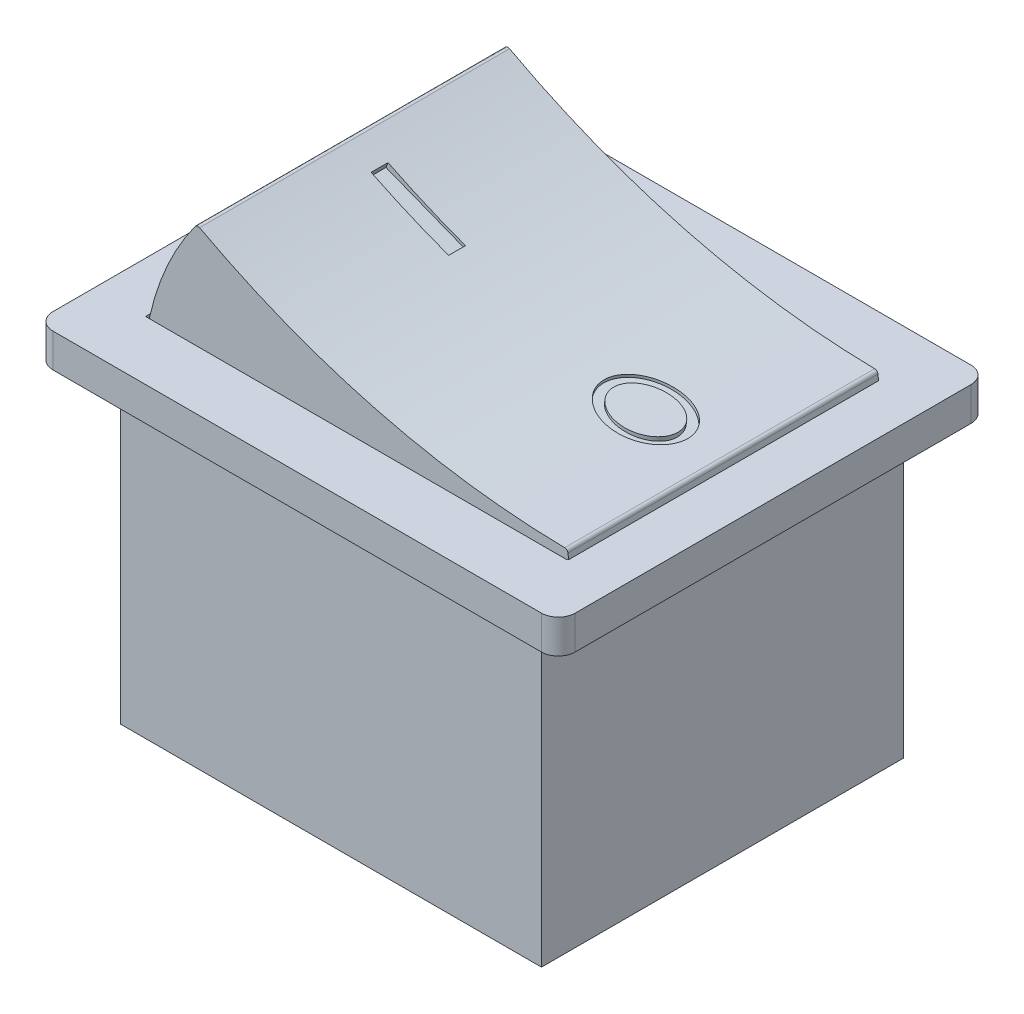
from build123d import *

# Parameters (mm, degrees)
CROQUIS1_W                   = 31
CROQUIS1_H                   = 25.5
CROQUIS1_W_2                 = 25
CROQUIS1_H_2                 = 18.5
SALIENTE_EXTRUIR1_DEPTH      = 2
REDONDEO1_R                  = 1
CROQUIS2_W                   = 25
CROQUIS2_H                   = 21.5
SALIENTE_EXTRUIR5_DEPTH      = 18.2
SALIENTE_EXTRUIR5_DEPTH_BACK = 1
SALIENTE_EXTRUIR6_DEPTH      = 10.75
SALIENTE_EXTRUIR7_DEPTH      = 9.2
CROQUIS7_RX                  = 2.5
CROQUIS7_RY                  = 1.989859087
CROQUIS7_RX_2                = 1.919157188
CROQUIS7_RY_2                = 1.506996734
CROQUIS7_W                   = 5
CROQUIS7_H                   = 1
CORTAR_EXTRUIR2_DEPTH        = 0.5
CROQUIS8_RX                  = 2.5
CROQUIS8_RY                  = 1.989859087
CROQUIS8_RX_2                = 1.919157188
CROQUIS8_RY_2                = 1.506996734
CROQUIS8_W                   = 5
CROQUIS8_H                   = 1
CORTAR_EXTRUIR3_DEPTH        = 0.5


with BuildPart() as part:
    # Croquis1 → Saliente-Extruir1 (new body)
    with BuildSketch(Plane(origin=(0, 0, 0), x_dir=(1, 0, 0), z_dir=(0, 1, 0))):
        Rectangle(CROQUIS1_W, CROQUIS1_H)
        Rectangle(CROQUIS1_W_2, CROQUIS1_H_2, mode=Mode.SUBTRACT)
    extrude(amount=SALIENTE_EXTRUIR1_DEPTH)

    # Redondeo1
    redondeo1_edges = [part.edges().sort_by_distance(p)[0] for p in [
        (15.5, 1, 12.75),
        (-15.5, 1, 12.75),
        (-15.5, 1, -12.75),
        (15.5, 1, -12.75),
    ]]
    fillet(redondeo1_edges, radius=REDONDEO1_R)

    # Croquis2 → Saliente-Extruir5 (add, two sides)
    with BuildSketch(Plane.XZ) as saliente_extruir5_sk:
        Rectangle(CROQUIS2_W, CROQUIS2_H)
    extrude(amount=SALIENTE_EXTRUIR5_DEPTH)
    extrude(saliente_extruir5_sk.sketch, amount=-SALIENTE_EXTRUIR5_DEPTH_BACK)

    # Croquis3 → Saliente-Extruir6 (add, symmetric)
    with BuildSketch(Plane.XY):
        with BuildLine():
            Line((12.5, 0), (13.5, 0))
            Line((13.5, 0), (13.5, -1))
            ThreePointArc((13.5, -1), (13.207106781, -1.707106781), (12.5, -2))
            Line((12.5, -2), (12.5, 0))
        make_face()
        with BuildLine():
            Line((-12.5, 0), (-12.5, -2))
            ThreePointArc((-12.5, -2), (-13.207106781, -1.707106781), (-13.5, -1))
            Line((-13.5, -1), (-13.5, 0))
            Line((-13.5, 0), (-12.5, 0))
        make_face()
    extrude(amount=SALIENTE_EXTRUIR6_DEPTH, both=True)

    # Croquis4 → Saliente-Extruir7 (add, symmetric)
    with BuildSketch(Plane.XY):
        with BuildLine():
            ThreePointArc((-9.347385872, 8.117762074), (1.152636372, 4.009298277), (12.326652836, 2.502215681))
            ThreePointArc((12.326652836, 2.502215681), (12.45734879, 2.45105267), (12.522240679, 2.326601358))
            ThreePointArc((12.522240679, 2.326601358), (12.589620665, 1.664412167), (12.62950875, 1))
            ThreePointArc((12.62950875, 1), (0.064754375, -1.4616694), (-12.5, 1))
            ThreePointArc((-12.5, 1), (-11.477075864, 4.704087901), (-9.603642409, 8.059216522))
            ThreePointArc((-9.603642409, 8.059216522), (-9.48648288, 8.136499966), (-9.347385872, 8.117762074))
        make_face()
    extrude(amount=SALIENTE_EXTRUIR7_DEPTH, both=True)

    # Croquis7 → Cortar-Extruir2 (cut, symmetric)
    with BuildSketch(Plane(origin=(1.513513313, 3.868093829, 0), x_dir=(-0.93125002, 0.364380846, 0), z_dir=(-0.364380846, -0.93125002, 0))):
        with Locations(Location((-7.5, 0), (0, 0, -180))):
            Ellipse(CROQUIS7_RX, CROQUIS7_RY)
        with Locations(Location((-7.5, 0), (0, 0, -180))):
            Ellipse(CROQUIS7_RX_2, CROQUIS7_RY_2, mode=Mode.SUBTRACT)
        with Locations((7.5, 0)):
            Rectangle(CROQUIS7_W, CROQUIS7_H)
    extrude(amount=CORTAR_EXTRUIR2_DEPTH, both=True, mode=Mode.SUBTRACT)

    # Croquis8 → Cortar-Extruir3 (cut, symmetric)
    with BuildSketch(Plane(origin=(0.55168143, 4.090351383, 0), x_dir=(-0.991026762, 0.133663593, 0), z_dir=(-0.133663593, -0.991026762, 0))):
        with Locations(Location((-7.5, 0), (0, 0, -180))):
            Ellipse(CROQUIS8_RX, CROQUIS8_RY)
        with Locations(Location((-7.5, 0), (0, 0, -180))):
            Ellipse(CROQUIS8_RX_2, CROQUIS8_RY_2, mode=Mode.SUBTRACT)
        with Locations((7.5, 0)):
            Rectangle(CROQUIS8_W, CROQUIS8_H)
    extrude(amount=CORTAR_EXTRUIR3_DEPTH, both=True, mode=Mode.SUBTRACT)


solid = part.part
